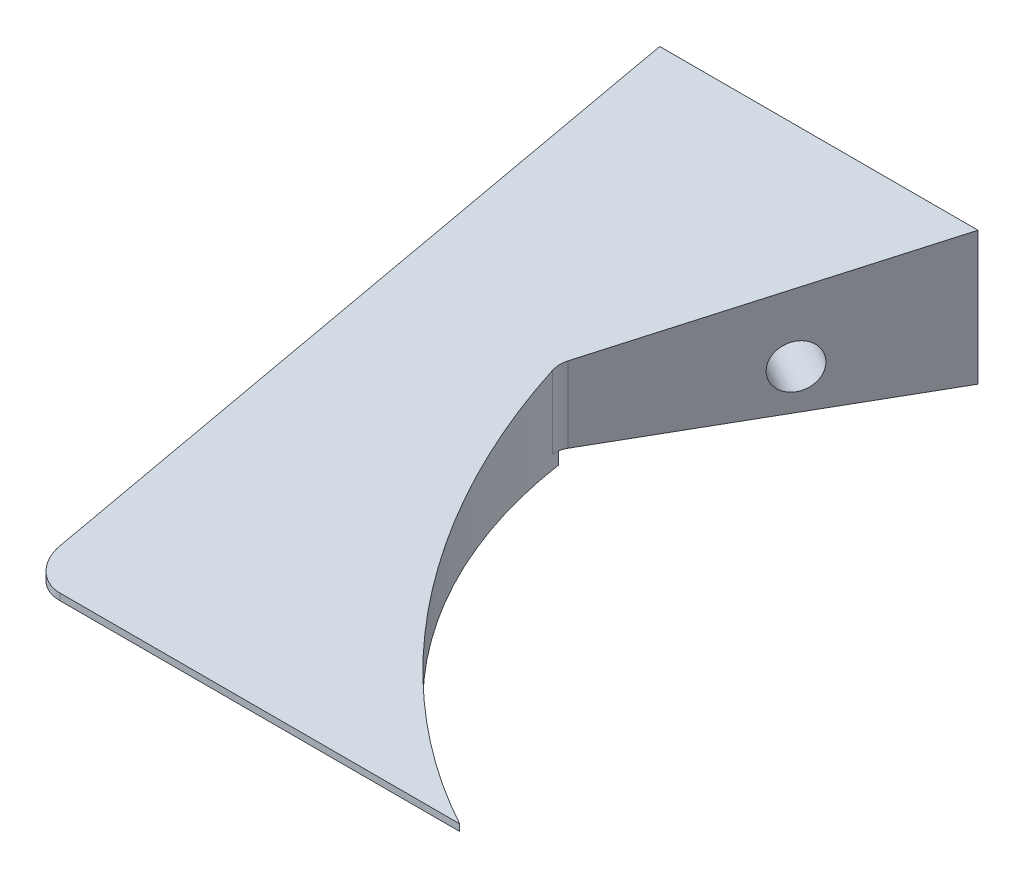
from build123d import *

# Parameters (mm, degrees)
ESBO_O1_W                                      = 130
ESBO_O1_H                                      = 22
RESSALTO_EXTRUS_O1_DEPTH                       = 95
CORTE_EXTRUS_O2_REACH                          = 24
CORTE_EXTRUS_O4_DEPTH                          = 1
CORTE_EXTRUS_O4_DEPTH_BACK                     = 66
BROCA_DE_ROSQUEAR_DE_CANO_PARA_TARRAXA_D_D     = 6.579997
BROCA_DE_ROSQUEAR_DE_CANO_PARA_TARRAXA_D_DEPTH = 10
BROCA_DE_ROSQUEAR_DE_CANO_PARA_TARRAXA_D_TIP   = 1.976830535
BROCA_DE_ROSQUEAR_DE_CANO_PARA_TARRA_2_D       = 6.579997
BROCA_DE_ROSQUEAR_DE_CANO_PARA_TARRA_2_DEPTH   = 10
BROCA_DE_ROSQUEAR_DE_CANO_PARA_TARRA_2_TIP     = 1.976830535
FILETE2_R                                      = 5
ESBO_O38_W                                     = 47.75
ESBO_O38_H                                     = 2
CORTE_EXTRUS_O9_DEPTH                          = 40
FILETE3_R                                      = 3


with BuildPart() as part:
    # Esboço1 → Ressalto-extrusão1 (new body)
    with BuildSketch(Plane.XY):
        Rectangle(ESBO_O1_W, ESBO_O1_H)
    extrude(amount=RESSALTO_EXTRUS_O1_DEPTH)

    # Esboço2 → Corte-extrusão2 (cut, up to next)
    with BuildSketch(Plane(origin=(0, 11, 0), x_dir=(1, 0, 0), z_dir=(0, 1, 0)), mode=Mode.PRIVATE) as corte_extrus_o2_sk1:
        with BuildLine():
            Line((65, 0), (-17.25, 0))
            Line((-17.25, 0), (-40.2, -40))
            ThreePointArc((-40.2, -40), (-26.859909281, -72.440879147), (0, -95))
            Line((0, -95), (65, -95))
            Line((65, -95), (65, 0))
        make_face()
    corte_extrus_o2_tool1 = extrude(corte_extrus_o2_sk1.sketch, amount=-CORTE_EXTRUS_O2_REACH, mode=Mode.PRIVATE) & part.part
    add(corte_extrus_o2_tool1.solids().sort_by_distance((18.11962, 11, 46.581028))[0], mode=Mode.SUBTRACT)

    # Esboço13 → Corte-extrusão4 (cut, two sides)
    with BuildSketch(Plane.ZY.offset(65)) as corte_extrus_o4_sk:
        Polygon((-200.195338438, 55.253706392), (0, 11), (95, -10), (295.195338438, -54.253706392), (383.702751221, 346.136970485), (-111.687925655, 455.644383268), align=None)
    extrude(amount=CORTE_EXTRUS_O4_DEPTH, mode=Mode.SUBTRACT)
    extrude(corte_extrus_o4_sk.sketch, amount=-CORTE_EXTRUS_O4_DEPTH_BACK, mode=Mode.SUBTRACT)

    # Broca de rosquear de cano para tarraxa d
    with Locations(Plane.ZY.offset(65)):
        with Locations((20, -3)):
            Hole(BROCA_DE_ROSQUEAR_DE_CANO_PARA_TARRAXA_D_D / 2, depth=BROCA_DE_ROSQUEAR_DE_CANO_PARA_TARRAXA_D_DEPTH)
            with Locations((0, 0, -(BROCA_DE_ROSQUEAR_DE_CANO_PARA_TARRAXA_D_DEPTH + BROCA_DE_ROSQUEAR_DE_CANO_PARA_TARRAXA_D_TIP / 2))):  # 118° drill point
                Cone(0, BROCA_DE_ROSQUEAR_DE_CANO_PARA_TARRAXA_D_D / 2, BROCA_DE_ROSQUEAR_DE_CANO_PARA_TARRAXA_D_TIP, mode=Mode.SUBTRACT)

    # Broca de rosquear de cano para tarra 2
    with Locations(Plane(origin=(-12.977837756, 0, -7.446034412), x_dir=(0.497656085, 0, -0.867374441), z_dir=(0.867374441, 0, 0.497656085))):
        with Locations((-28.584567474, -3)):
            Hole(BROCA_DE_ROSQUEAR_DE_CANO_PARA_TARRA_2_D / 2, depth=BROCA_DE_ROSQUEAR_DE_CANO_PARA_TARRA_2_DEPTH)
            with Locations((0, 0, -(BROCA_DE_ROSQUEAR_DE_CANO_PARA_TARRA_2_DEPTH + BROCA_DE_ROSQUEAR_DE_CANO_PARA_TARRA_2_TIP / 2))):  # 118° drill point
                Cone(0, BROCA_DE_ROSQUEAR_DE_CANO_PARA_TARRA_2_D / 2, BROCA_DE_ROSQUEAR_DE_CANO_PARA_TARRA_2_TIP, mode=Mode.SUBTRACT)

    # Filete2
    filete2_edges = [part.edges().sort_by_distance(p)[0] for p in [
        (-65, -10.5, 95),
    ]]
    fillet(filete2_edges, radius=FILETE2_R)

    # Esboço38 → Corte-extrusão9 (cut)
    with BuildSketch(Plane(origin=(0, 0, 0), x_dir=(-1, 0, 0), z_dir=(0, 0, -1))):
        with Locations((41.125, -10)):
            Rectangle(ESBO_O38_W, ESBO_O38_H)
    extrude(amount=-CORTE_EXTRUS_O9_DEPTH, mode=Mode.SUBTRACT)

    # Filete3
    filete3_edges = [part.edges().sort_by_distance(p)[0] for p in [
        (-40.2, -3.421052632, 40),
    ]]
    fillet(filete3_edges, radius=FILETE3_R)


solid = part.part
